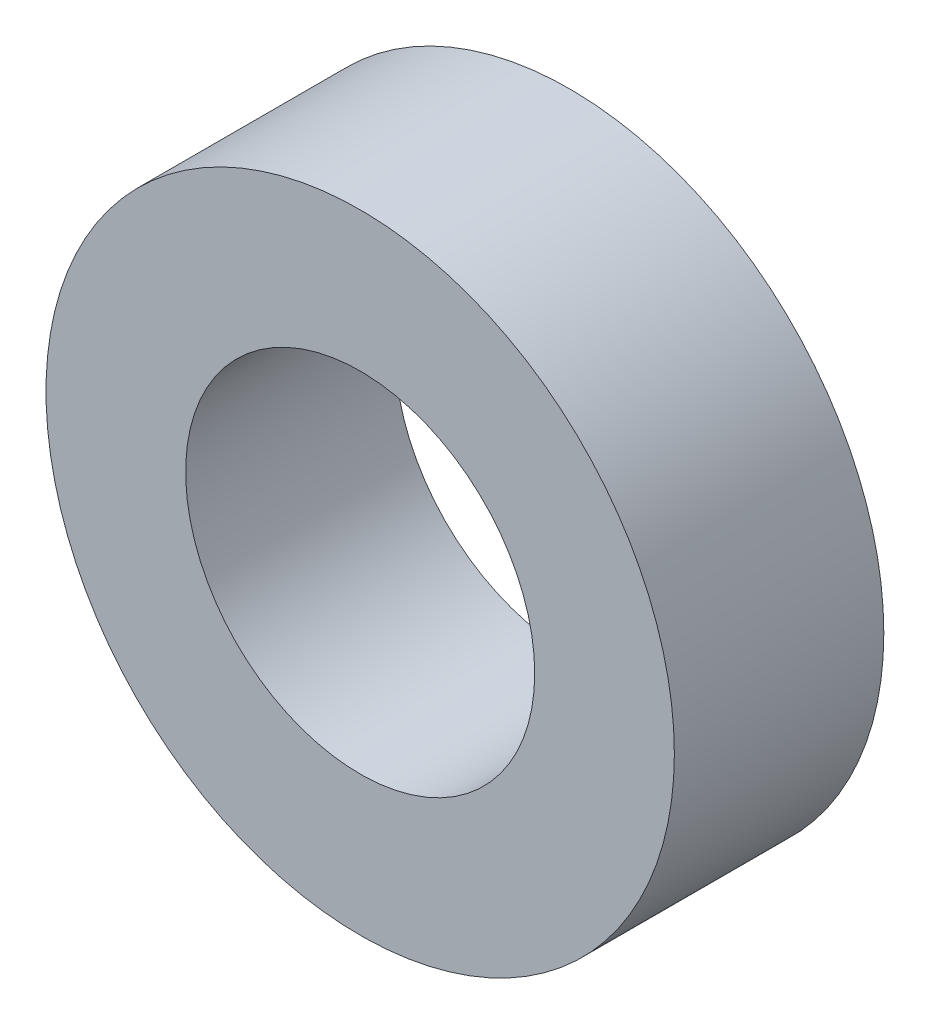
from build123d import *

# Parameters (mm, degrees)
CROQUIS1_R              = 4.5
CROQUIS1_R_2            = 2.5
SALIENTE_EXTRUIR1_DEPTH = 3


with BuildPart() as part:
    # Croquis1 → Saliente-Extruir1 (new body)
    with BuildSketch(Plane.XY):
        Circle(CROQUIS1_R)
        Circle(CROQUIS1_R_2, mode=Mode.SUBTRACT)
    extrude(amount=SALIENTE_EXTRUIR1_DEPTH)


solid = part.part
